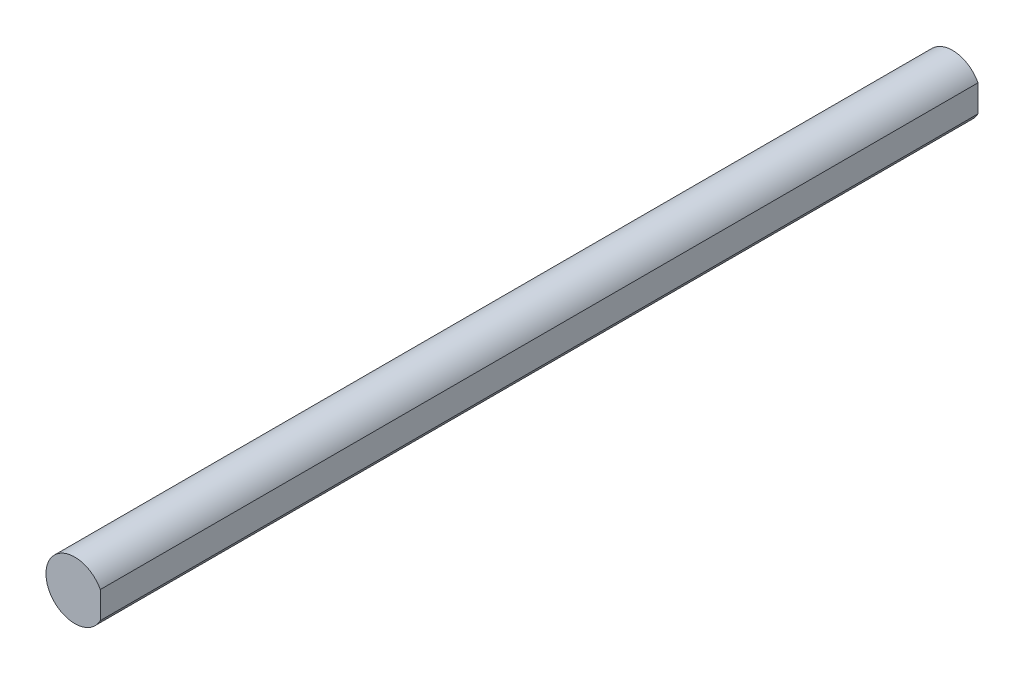
from build123d import *

# Parameters (mm, degrees)
BOSS_EXTRUDE2_DEPTH = 88.9


with BuildPart() as part:
    # Sketch2 → Boss-Extrude2 (new body)
    with BuildSketch(Plane.XY):
        with BuildLine():
            ThreePointArc((2.584327422, 1.361430415), (-2.921, 0), (2.584327422, -1.361430415))
            Line((2.584327422, -1.361430415), (2.584327422, 1.361430415))
        make_face()
    extrude(amount=BOSS_EXTRUDE2_DEPTH)


solid = part.part
